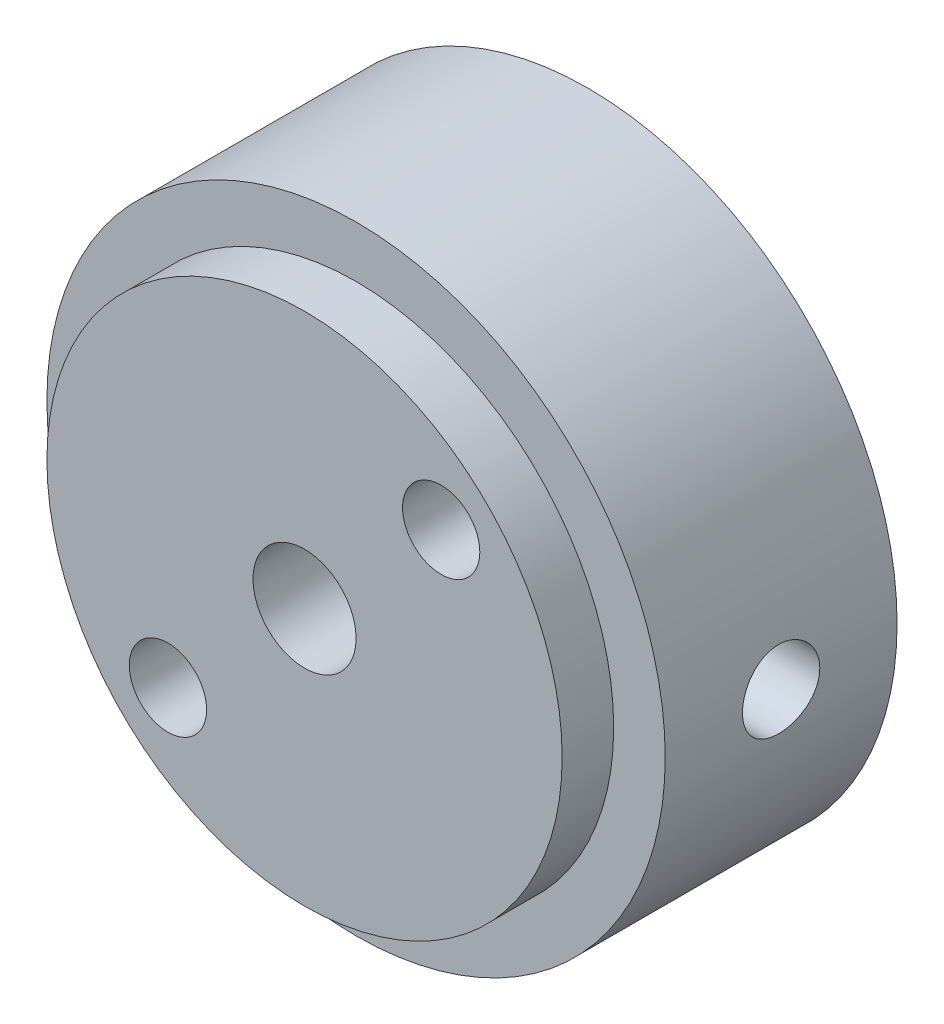
from build123d import *

# Parameters (mm, degrees)
ESQUISSE1_R                  = 12
BOSS_EXTRU_1_DEPTH           = 9
ESQUISSE2_R                  = 10
BOSS_EXTRU_2_DEPTH           = 2
ESQUISSE3_R                  = 1.5
ESQUISSE3_R_2                = 2
ENL_V_MAT_EXTRU_1_DEPTH      = 12
ESQUISSE4_R                  = 1.5
ENL_V_MAT_EXTRU_2_DEPTH      = 13
R_P_TITION_CIRCULAIRE1_COUNT = 2
R_P_TITION_CIRCULAIRE1_ANGLE = 90


with BuildPart() as part:
    # Esquisse1 → Boss.-Extru.1 (new body)
    with BuildSketch(Plane.XY):
        Circle(ESQUISSE1_R)
    extrude(amount=BOSS_EXTRU_1_DEPTH)

    # Esquisse2 → Boss.-Extru.2 (add)
    with BuildSketch(Plane.XY.offset(9)):
        Circle(ESQUISSE2_R)
    extrude(amount=BOSS_EXTRU_2_DEPTH)

    # Esquisse3 → Enlèv. mat.-Extru.1 (cut, through all)
    with BuildSketch(Plane.XY.offset(11)):
        with Locations((-5.303300859, -5.303300859)):
            Circle(ESQUISSE3_R)
        with Locations((5.303300859, 5.303300859)):
            Circle(ESQUISSE3_R)
        Circle(ESQUISSE3_R_2)
    extrude(amount=-ENL_V_MAT_EXTRU_1_DEPTH, mode=Mode.SUBTRACT)

    # Esquisse4 → Enlèv. mat.-Extru.2 (cut, through all)
    with BuildSketch(Plane(origin=(0, 0, 0), x_dir=(1, 0, 0), z_dir=(0, 1, 0))):
        with Locations((0, -4.5)):
            Circle(ESQUISSE4_R)
    enl_v_mat_extru_2 = extrude(amount=-ENL_V_MAT_EXTRU_2_DEPTH, mode=Mode.SUBTRACT)

    # Répétition circulaire1: Enlèv. mat.-Extru.2 ×2 about axis
    r_p_tition_circulaire1_axis = Axis((0, 0, 9), (0, 0, 1))
    for i in range(1, R_P_TITION_CIRCULAIRE1_COUNT):
        add(enl_v_mat_extru_2.rotate(r_p_tition_circulaire1_axis, i * R_P_TITION_CIRCULAIRE1_ANGLE / (R_P_TITION_CIRCULAIRE1_COUNT - 1)), mode=Mode.SUBTRACT)


solid = part.part
